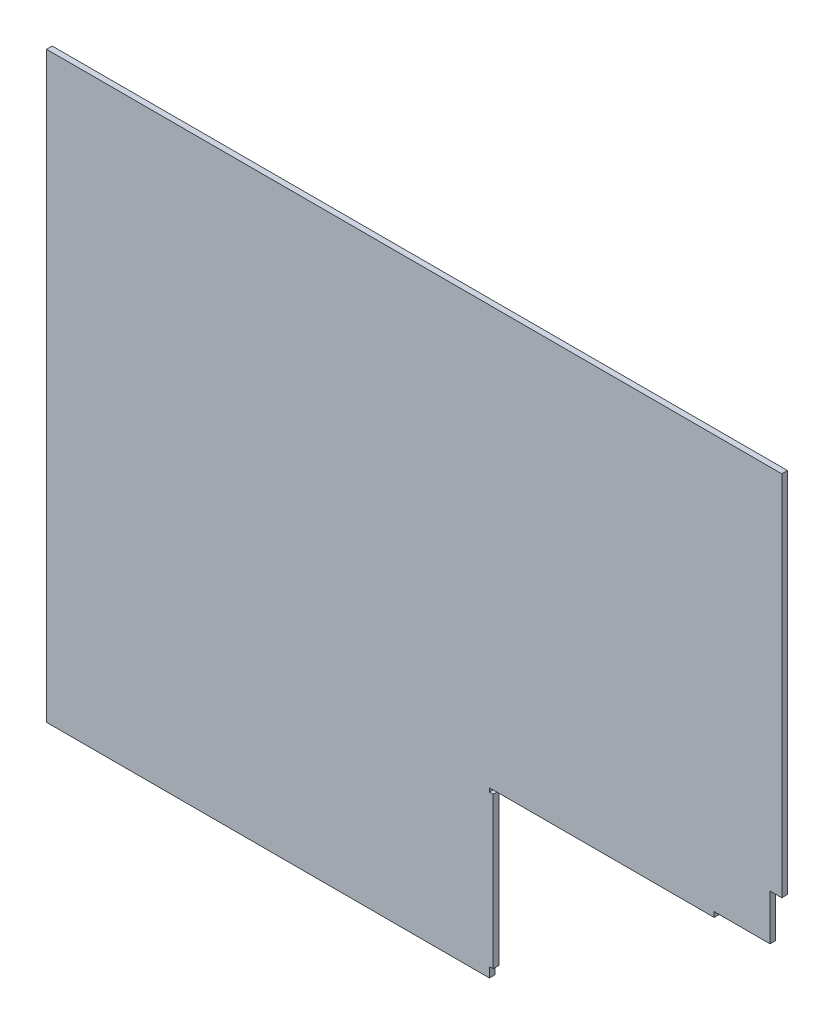
from build123d import *

# Parameters (mm, degrees)
SKETCH1_W           = 579
SKETCH1_H           = 459
BOSS_EXTRUDE1_DEPTH = 2.2479
CUT_EXTRUDE1_DEPTH  = 4.4958


with BuildPart() as part:
    # Sketch1 → Boss-Extrude1 (new body, symmetric)
    with BuildSketch(Plane.XY):
        Rectangle(SKETCH1_W, SKETCH1_H)
    extrude(amount=BOSS_EXTRUDE1_DEPTH, both=True)

    # Sketch2 → Cut-Extrude1 (cut)
    with BuildSketch(Plane(origin=(0, 0, -2.2479), x_dir=(-1, 0, 0), z_dir=(0, 0, -1))):
        Polygon((-280.249993563, -59.7), (-290, -59.7), (-290, -230), (-59.249993563, -230), (-59.249993563, -221.7), (-62.249993563, -221.7), (-62.249993563, -102.7), (-59.249993563, -102.7), (-59.249993563, -99.7), (-236.249993563, -99.7), (-236.249993563, -95.7), (-280.249993563, -95.7), align=None)
    extrude(amount=-CUT_EXTRUDE1_DEPTH, mode=Mode.SUBTRACT)


solid = part.part
